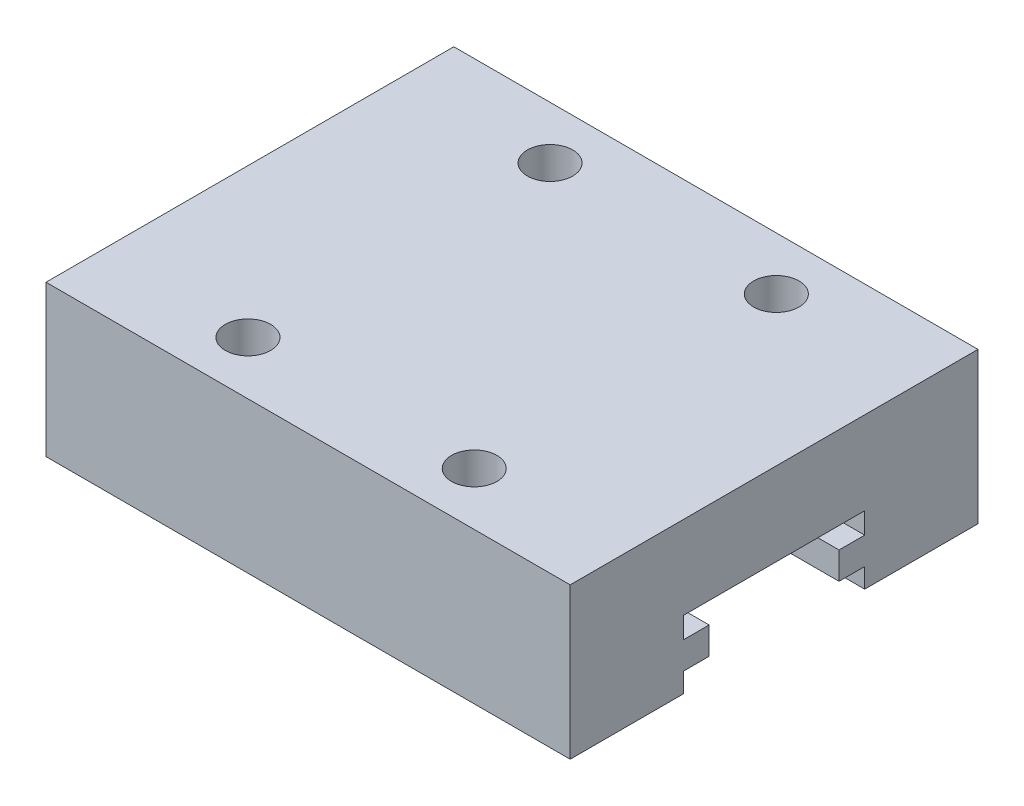
from build123d import *

# Parameters (mm, degrees)
CROQUIS1_W              = 34.7
CROQUIS1_H              = 27
SALIENTE_EXTRUIR1_DEPTH = 10
CROQUIS2_R              = 1.5
CORTAR_EXTRUIR1_DEPTH   = 5
CORTAR_EXTRUIR2_DEPTH   = 34.7


with BuildPart() as part:
    # Croquis1 → Saliente-Extruir1 (new body)
    with BuildSketch(Plane(origin=(0, 0, 0), x_dir=(1, 0, 0), z_dir=(0, 1, 0))):
        with Locations((17.35, 13.5)):
            Rectangle(CROQUIS1_W, CROQUIS1_H)
    extrude(amount=SALIENTE_EXTRUIR1_DEPTH)

    # Croquis2 → Cortar-Extruir1 (cut)
    with BuildSketch(Plane(origin=(0, 10, 0), x_dir=(1, 0, 0), z_dir=(0, 1, 0))):
        with Locations((9.85, 23.52014925)):
            Circle(CROQUIS2_R)
        with Locations((24.849986467, 23.5)):
            Circle(CROQUIS2_R)
        with Locations((9.85, 3.52014925)):
            Circle(CROQUIS2_R)
        with Locations((24.849986467, 3.5)):
            Circle(CROQUIS2_R)
    extrude(amount=-CORTAR_EXTRUIR1_DEPTH, mode=Mode.SUBTRACT)

    # Croquis3 → Cortar-Extruir2 (cut)
    with BuildSketch(Plane(origin=(34.7, 0, 0), x_dir=(0, 0, -1), z_dir=(1, 0, 0))):
        Polygon((7.5, 0), (19.5, 0), (19.5, 1.3), (17.8, 1.3), (17.8, 3.1), (19.5, 3.1), (19.5, 4.5), (7.5, 4.5), (7.5, 3.1), (9.2, 3.1), (9.2, 1.3), (7.5, 1.3), align=None)
    extrude(amount=-CORTAR_EXTRUIR2_DEPTH, mode=Mode.SUBTRACT)


solid = part.part
